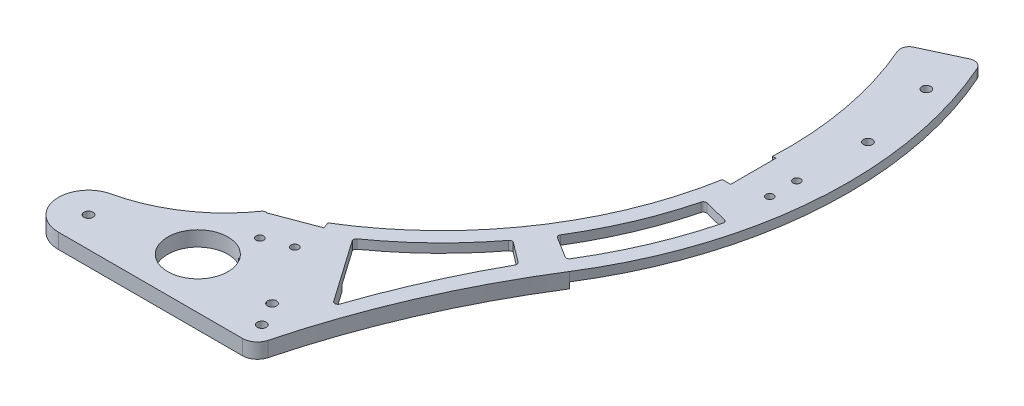
from build123d import *

# Parameters (mm, degrees)
EXTRUDE_1_DEPTH     = 3
CUT_EXTRUDE_1_DEPTH = 5
EXTRUDE_2_DEPTH     = 5
SKETCH_4_R          = 1.25
SKETCH_4_R_2        = 1.5
SKETCH_4_W          = 3
SKETCH_4_H          = 15
CUT_EXTRUDE_2_DEPTH = 5
FILLET_1_R          = 3
FILLET_2_R          = 5
SKETCH_5_R          = 10
SKETCH_5_R_2        = 1.5
CUT_EXTRUDE_3_DEPTH = 10
FILLET_3_R          = 1


with BuildPart() as part:
    # 草图1 → 凸台-拉伸1 (new body)
    with BuildSketch(Plane(origin=(0, 0, 0), x_dir=(1, 0, 0), z_dir=(0, 1, 0))):
        with BuildLine():
            Line((0, 0), (0, -135))
            ThreePointArc((0, -135), (113.857845185, -72.535447127), (122.35155125, 57.053465335))
            Line((122.35155125, 57.053465335), (0, 0))
        make_face()
    extrude(amount=EXTRUDE_1_DEPTH)

    # 草图2 → 切除-拉伸1 (cut)
    with BuildSketch(Plane(origin=(0, 3, 0), x_dir=(1, 0, 0), z_dir=(0, 1, 0))):
        with BuildLine():
            Line((0, 0), (104.225395509, 48.6011001))
            ThreePointArc((104.225395509, 48.6011001), (107.568320743, -40.670091868), (46, -105.399240984))
            Line((46, -105.399240984), (54, -123.729543764))
            ThreePointArc((54, -123.729543764), (27.581801898, -132.152352246), (0, -135))
            Line((0, -135), (0, 0))
        make_face()
    extrude(amount=-CUT_EXTRUDE_1_DEPTH, mode=Mode.SUBTRACT)

    # 草图3 → 凸台-拉伸2 (add)
    with BuildSketch(Plane(origin=(0, 3, 0), x_dir=(1, 0, 0), z_dir=(0, 1, 0))):
        with BuildLine():
            Line((46, -105.399240984), (54, -123.729543764))
            ThreePointArc((54, -123.729543764), (88.040639509, -102.341808636), (114.273799591, -71.878360632))
            ThreePointArc((114.273799591, -71.878360632), (95.730838943, -107.385901313), (83.09704134, -145.399240984))
            Line((83.09704134, -145.399240984), (18.09704134, -145.399240984))
            ThreePointArc((18.09704134, -145.399240984), (8.158015649, -136.501859828), (15.905249936, -125.642394647))
            ThreePointArc((15.905249936, -125.642394647), (32.852844555, -118.345804202), (46, -105.399240984))
        make_face()
    extrude(amount=-EXTRUDE_2_DEPTH)

    # 草图4 → 切除-拉伸2 (cut)
    with BuildSketch(Plane(origin=(0, 3, 0), x_dir=(1, 0, 0), z_dir=(0, 1, 0))):
        with Locations((126, -8)):
            Circle(SKETCH_4_R)
        with Locations((126, -17)):
            Circle(SKETCH_4_R)
        with Locations((18.09704134, -135.399240984)):
            Circle(SKETCH_4_R_2)
        with Locations((53.261619346, -113.641470943)):
            Circle(SKETCH_4_R)
        with Locations((61.682428963, -110.465000355)):
            Circle(SKETCH_4_R)
        with Locations((121.091047045, 39.915013787)):
            Circle(SKETCH_4_R_2)
        with Locations((126.614572621, 15)):
            Circle(SKETCH_4_R_2)
        Polygon((59.901130208, -97.242785157), (60.959953737, -100.049721696), (46.925271043, -105.343839343), (45.866447513, -102.536902804), align=None)
        with Locations((114.5, -12.5)):
            Rectangle(SKETCH_4_W, SKETCH_4_H)
    extrude(amount=-CUT_EXTRUDE_2_DEPTH, mode=Mode.SUBTRACT)

    # 圆角1
    fillet_1_edges = [part.edges().sort_by_distance(p)[0] for p in [
        (104.225395509, 1.5, -48.6011001),
        (122.35155125, 1.5, -57.053465335),
    ]]
    fillet(fillet_1_edges, radius=FILLET_1_R)

    # 圆角2
    fillet_2_edges = [part.edges().sort_by_distance(p)[0] for p in [
        (83.09704134, 0.5, 145.399240984),
    ]]
    fillet(fillet_2_edges, radius=FILLET_2_R)

    # 草图5 → 切除-拉伸3 (cut)
    with BuildSketch(Plane(origin=(0, 3, 0), x_dir=(1, 0, 0), z_dir=(0, 1, 0))):
        with Locations((47.633497714, -128.622545035)):
            Circle(SKETCH_5_R)
        with Locations((78.536756787, -138.249693791)):
            Circle(SKETCH_5_R_2)
        with Locations((74.091279988, -130.424239426)):
            Circle(SKETCH_5_R_2)
        with BuildLine():
            Line((68.829172362, -98.298245315), (84.88931258, -121.234502555))
            ThreePointArc((84.88931258, -121.234502555), (93.343637557, -99.289475714), (103.822616306, -78.23595301))
            Line((103.822616306, -78.23595301), (95.836261206, -72.217802778))
            ThreePointArc((95.836261206, -72.217802778), (83.359004455, -86.320776041), (68.829172362, -98.298245315))
        make_face()
        with BuildLine():
            Line((101.765771539, -63.590311708), (110.2462525, -68.88950435))
            ThreePointArc((110.2462525, -68.88950435), (119.665630949, -50.795046704), (126.138444416, -31.449846428))
            Line((126.138444416, -31.449846428), (116.435487153, -29.030627472))
            ThreePointArc((116.435487153, -29.030627472), (110.460582414, -46.887735419), (101.765771539, -63.590311708))
        make_face()
    extrude(amount=-CUT_EXTRUDE_3_DEPTH, mode=Mode.SUBTRACT)

    # 圆角3
    fillet_3_edges = [part.edges().sort_by_distance(p)[0] for p in [
        (101.765771539, 1.5, 63.590311708),
        (116.435487153, 1.5, 29.030627472),
        (126.138444416, 1.5, 31.449846428),
        (110.2462525, 1.5, 68.88950435),
        (68.829172362, 1.5, 98.298245315),
        (95.836261206, 1.5, 72.217802778),
        (103.822616306, 1.5, 78.23595301),
        (84.88931258, 0.5, 121.234502555),
    ]]
    fillet(fillet_3_edges, radius=FILLET_3_R)


solid = part.part
